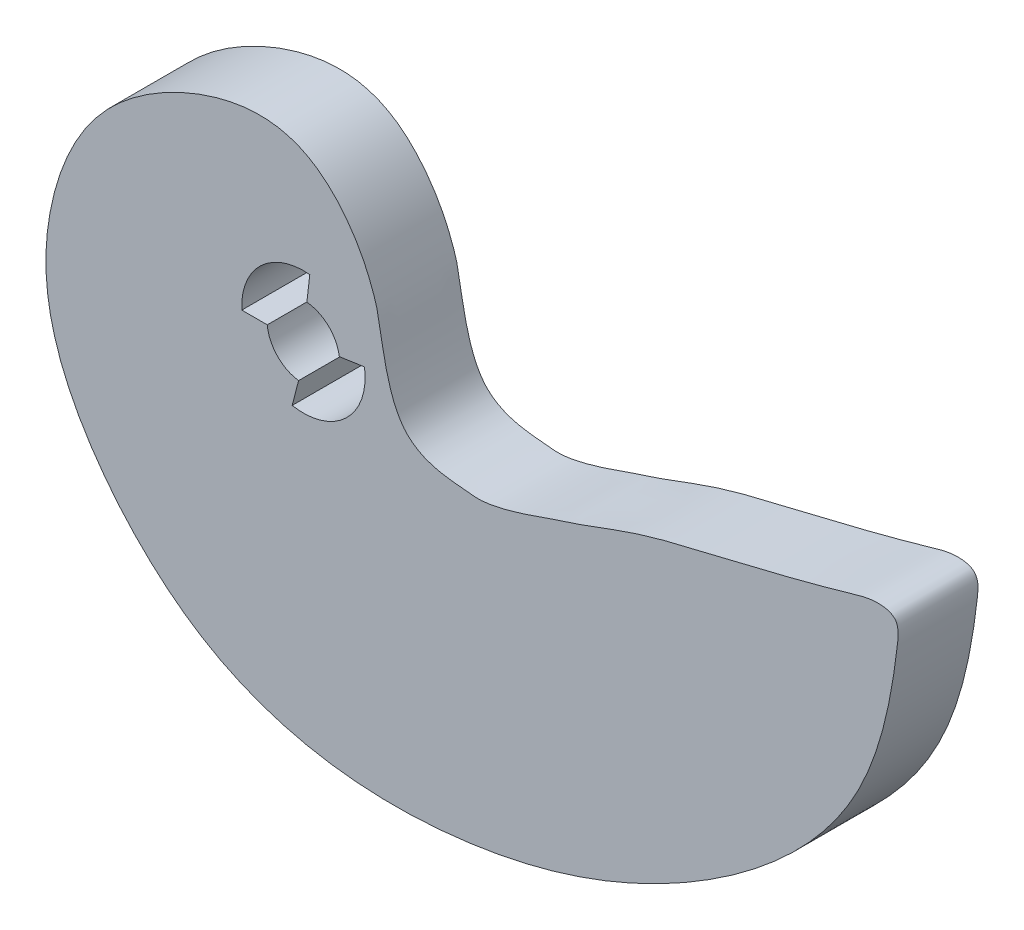
from build123d import *

# Parameters (mm, degrees)
SCHIZZO1_R                   = 2.5
ESTRUSIONE_ESTRUSIONE1_DEPTH = 5.5
TAGLIO_ESTRUSIONE1_DEPTH     = 10


with BuildPart() as part:
    # Schizzo1 → Estrusione-Estrusione1 (new body)
    with BuildSketch(Plane.XY):
        with BuildLine():
            add(Edge.make_bspline(
                [(-75.824153285, -114.26682019), (-77.155722135, -112.607928015), (-77.380650265, -108.904511464), (-77.812138775, -107.611985546), (-78.391774348, -105.871169977), (-80.72485053, -101.841420768), (-85.990570093, -99.17046831), (-96.907912796, -104.28760714), (-101.038879113, -113.876150436), (-100.288690876, -123.302763721), (-89.269468366, -136.537216553), (-73.195865931, -138.052646927), (-57.455738051, -133.369952636), (-44.691537743, -123.535203139), (-42.254163283, -114.266033288), (-41.654561184, -108.48062384), (-43.466224946, -108.263753116), (-48.053631516, -109.641165444), (-52.39406684, -110.660212358), (-60.647774842, -112.651012095), (-62.506863678, -113.612081966), (-64.545834483, -114.220651877), (-65.845244128, -114.642388058), (-69.596857974, -116.123048026), (-72.135934347, -115.757636844), (-74.672618994, -115.701422107), (-75.824153285, -114.26682019)],
                knots=[0, 0, 0, 0, 0.019605482, 0.020637349, 0.022128875, 0.050467862, 0.122903141, 0.200131012, 0.266977293, 0.348315635, 0.42998504, 0.551961091, 0.645021424, 0.750991935, 0.821689296, 0.830772391, 0.840595049, 0.848258209, 0.899740831, 0.910874378, 0.95080925, 0.95315836, 0.954558513, 0.97836111, 0.983045274, 1, 1, 1, 1], degree=3))
        make_face()
        with Locations((-82.747083107, -112.580968106)):
            Circle(SCHIZZO1_R, mode=Mode.SUBTRACT)
    extrude(amount=ESTRUSIONE_ESTRUSIONE1_DEPTH)

    # Schizzo2 → Taglio-Estrusione1 (cut)
    with BuildSketch(Plane.XY.offset(5.5)):
        with BuildLine():
            Line((-82.509186121, -110.092312842), (-82.308527744, -108.353655817))
            ThreePointArc((-82.308527744, -108.353655817), (-85.676965681, -109.502285255), (-86.990921502, -112.809738024))
            Line((-86.990921502, -112.809738024), (-85.236593967, -112.809738024))
            ThreePointArc((-85.236593967, -112.809738024), (-84.511606035, -110.809963071), (-82.509186121, -110.092312842))
        make_face()
        with BuildLine():
            Line((-83.080409832, -115.05864712), (-83.520579374, -116.759987552))
            ThreePointArc((-83.520579374, -116.759987552), (-79.80120945, -115.644353227), (-78.541018579, -111.971442726))
            Line((-78.541018579, -111.971442726), (-80.27233286, -112.226551379))
            ThreePointArc((-80.27233286, -112.226551379), (-80.971804186, -114.341191034), (-83.080409832, -115.05864712))
        make_face()
    extrude(amount=-TAGLIO_ESTRUSIONE1_DEPTH, mode=Mode.SUBTRACT)


solid = part.part
